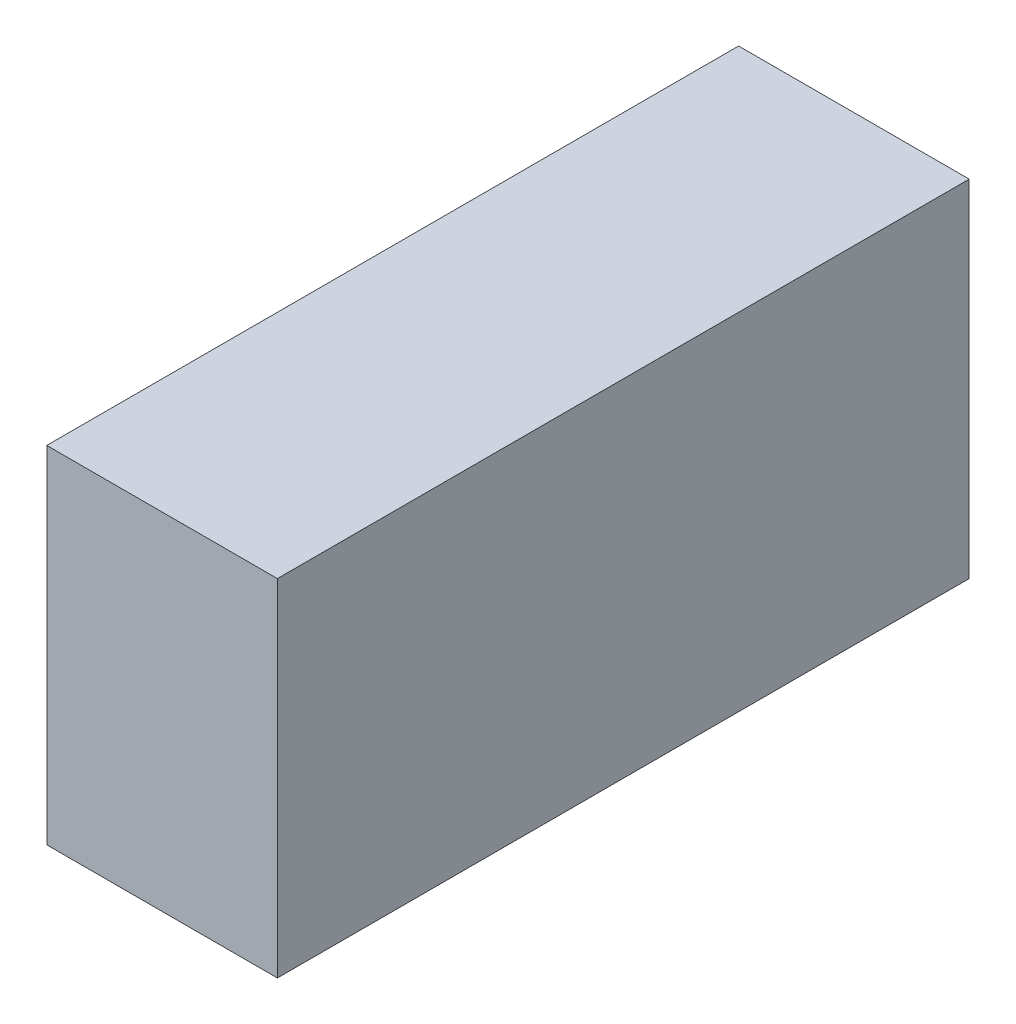
from build123d import *

# Parameters (mm, degrees)
SKETCH1_W                  = 914.4
SKETCH1_H                  = 457.2
MAIN_ENCLOSURE_MODEL_DEPTH = 304.8


with BuildPart() as part:
    # Sketch1 → Main Enclosure Model (new body)
    with BuildSketch(Plane(origin=(0, 0, 0), x_dir=(0, 0, -1), z_dir=(1, 0, 0))):
        with Locations((457.2, 228.6)):
            Rectangle(SKETCH1_W, SKETCH1_H)
    extrude(amount=MAIN_ENCLOSURE_MODEL_DEPTH)


solid = part.part
